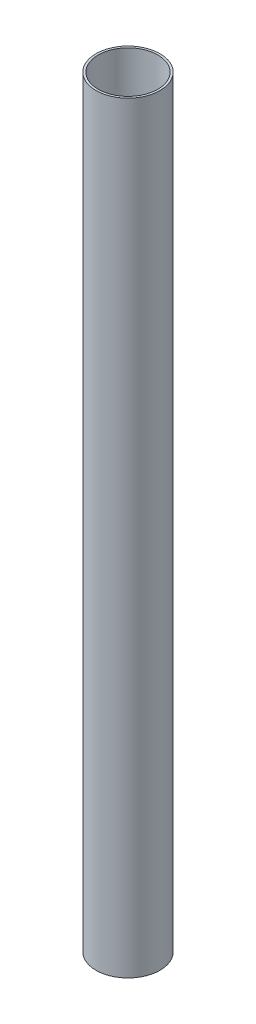
from build123d import *

# Parameters (mm, degrees)
SKETCH1_R           = 29.3685
SKETCH1_R_2         = 27.3685
BOSS_EXTRUDE1_DEPTH = 700


with BuildPart() as part:
    # Sketch1 → Boss-Extrude1 (new body)
    with BuildSketch(Plane(origin=(0, 0, 0), x_dir=(1, 0, 0), z_dir=(0, 1, 0))):
        Circle(SKETCH1_R)
        Circle(SKETCH1_R_2, mode=Mode.SUBTRACT)
    extrude(amount=BOSS_EXTRUDE1_DEPTH)


solid = part.part
